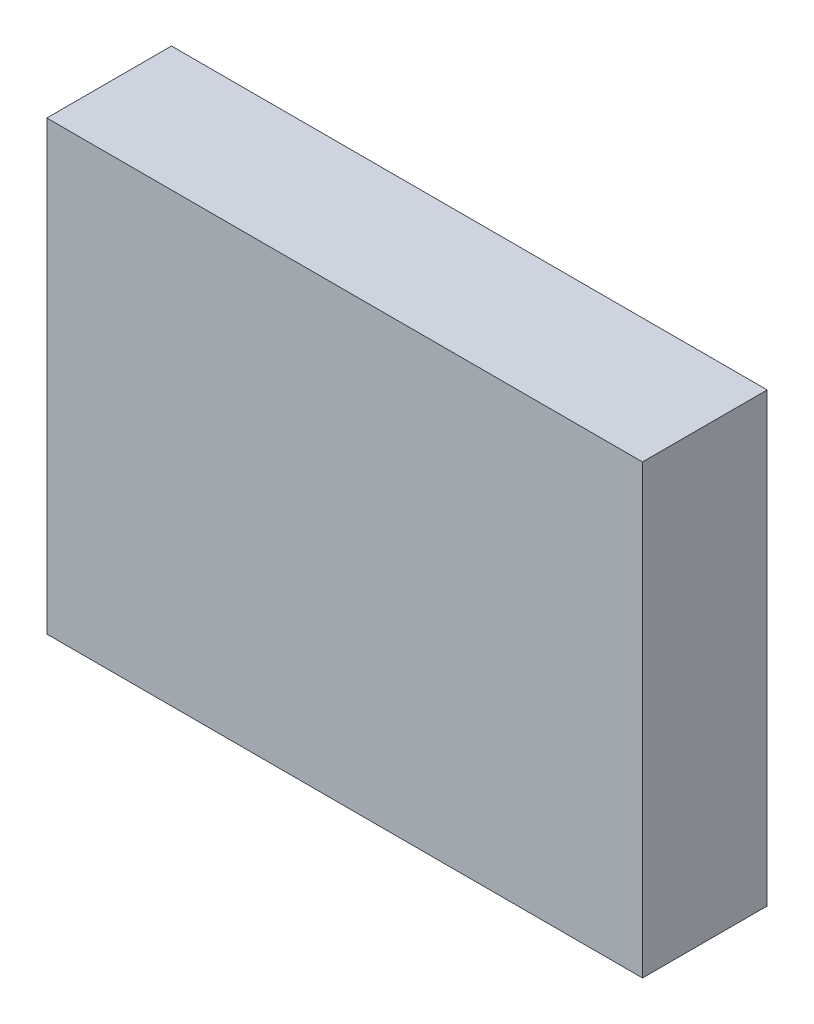
from build123d import *

# Parameters (mm, degrees)
BOSS_EXTRUDE1_DEPTH      = 18
BOSS_EXTRUDE1_2_DEPTH    = 18
SKETCH4_W                = 109.870132399
SKETCH4_H                = 82.433439447
BOSS_EXTRUDE2_DEPTH      = 5
BOSS_EXTRUDE2_DEPTH_BACK = 18


with BuildPart() as part:
    # Sketch2 → Boss-Extrude1 (new body)
    with BuildSketch(Plane.XY):
        with BuildLine():
            Line((41.451402768, 78.627112804), (62.71779308, 78.432008305))
            Line((62.71779308, 78.432008305), (62.71779308, 64.38448443))
            Line((62.71779308, 64.38448443), (59.596121107, 64.38448443))
            Line((59.596121107, 64.38448443), (59.596121107, 25.94889827))
            Line((59.596121107, 25.94889827), (50.426209689, 15.998568858))
            Line((50.426209689, 15.998568858), (32.866804844, 16.193673357))
            add(Edge.make_bspline(
                [(32.866804844, 16.193673357), (31.910610057, 17.627965538), (24.872485991, 25.751722249), (24.867520415, 26.144002768), (24.804131767, 31.151705999), (24.997590081, 36.159367013), (25.062624913, 41.167049135)],
                knots=[0, 0, 0, 0, 1, 1, 1, 2, 2, 2, 2], degree=3))
            Line((25.062624913, 41.167049135), (38.719939792, 40.971944637))
            Line((38.719939792, 40.971944637), (38.719939792, 30.241197232))
            Line((38.719939792, 30.241197232), (44.182865744, 30.241197232))
            Line((44.182865744, 30.241197232), (45.74370173, 32.582451211))
            Line((45.74370173, 32.582451211), (45.548597232, 64.38448443))
            Line((45.548597232, 64.38448443), (41.25629827, 64.38448443))
            Line((41.25629827, 64.38448443), (41.451402768, 78.627112804))
        make_face()
    extrude(amount=BOSS_EXTRUDE1_DEPTH)


with BuildPart() as body_2:
    # Sketch2 → Boss-Extrude1 2 (new body)
    with BuildSketch(Plane.XY):
        Polygon((73.021358937, 78.862525948), (105.897964848, 78.61155949), (114.932757312, 68.070968282), (114.681790855, 49.750416896), (105.897964848, 42.723356091), (90.338044493, 42.472389633), (90.572819566, 27.916335108), (93.600608438, 27.916335108), (93.600608438, 18.630576186), (73.021358937, 18.630576186), (73.021358937, 27.916335108), (78.040688083, 27.916335108), (78.040688083, 69.827733483), (73.021358937, 69.827733483), align=None)
        Polygon((88.530273253, 69.827733483), (88.530273253, 53.164474994), (99.086194651, 53.164474994), (103.268762855, 56.749533454), (103.268762855, 64.948070578), (99.086194651, 69.827733483), align=None, mode=Mode.SUBTRACT)
    extrude(amount=BOSS_EXTRUDE1_2_DEPTH)


with BuildPart() as body_3:
    # Sketch4 → Boss-Extrude2 (new body, two sides)
    with BuildSketch(Plane.XY.offset(18)) as boss_extrude2_sk:
        with Locations((69.997691113, 47.410393081)):
            Rectangle(SKETCH4_W, SKETCH4_H)
    extrude(amount=BOSS_EXTRUDE2_DEPTH)
    extrude(boss_extrude2_sk.sketch, amount=-BOSS_EXTRUDE2_DEPTH_BACK)

    # Combine1: cut part, body 2
    add(part.part, mode=Mode.SUBTRACT)
    add(body_2.part, mode=Mode.SUBTRACT)


solid = body_3.part
